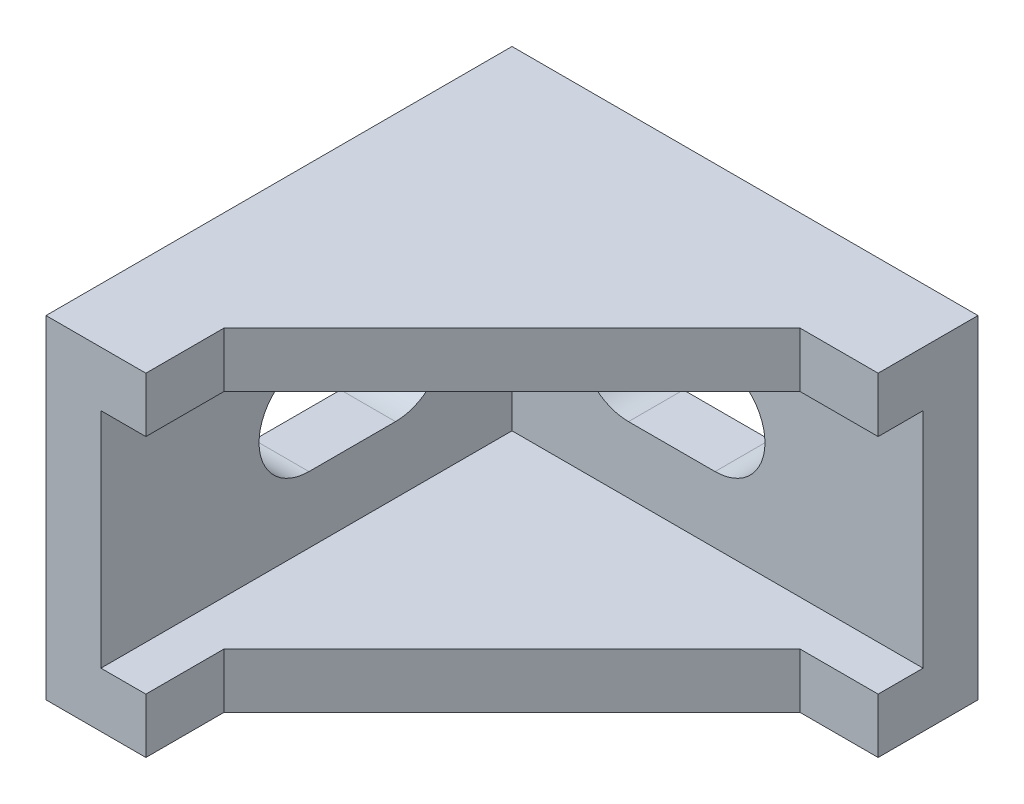
from build123d import *

# Parameters (mm, degrees)
SKETCH1_W           = 28
SKETCH1_H           = 20
BOSS_EXTRUDE1_DEPTH = 3.3
BOSS_EXTRUDE2_DEPTH = 10
SKETCH3_W           = 24.7
SKETCH3_H           = 13.4
CUT_EXTRUDE1_DEPTH  = 24.7


with BuildPart() as part:
    # Sketch1 → Boss-Extrude1 (new body)
    with BuildSketch(Plane(origin=(0, 0, 0), x_dir=(0, 0, -1), z_dir=(1, 0, 0))):
        with Locations((14, 10)):
            Rectangle(SKETCH1_W, SKETCH1_H)
        with BuildLine():
            Line((12.5, 13.28), (17.7, 13.28))
            ThreePointArc((17.7, 13.28), (20.7, 10.28), (17.7, 7.28))
            Line((17.7, 7.28), (12.5, 7.28))
            ThreePointArc((12.5, 7.28), (9.5, 10.28), (12.5, 13.28))
        make_face(mode=Mode.SUBTRACT)
    boss_extrude1 = extrude(amount=BOSS_EXTRUDE1_DEPTH)

    # Mirror1: Boss-Extrude1 across plane
    add(boss_extrude1.mirror(Plane(origin=(14, 0, -14), x_dir=(0.707106781, 0, 0.707106781), z_dir=(-0.707106781, 0, 0.707106781))))

    # Sketch2 → Boss-Extrude2 (add, symmetric)
    with BuildSketch(Plane(origin=(0, 10, 0), x_dir=(1, 0, 0), z_dir=(0, 1, 0))):
        Polygon((3.3, 0), (6, 0), (6, 4.7), (23.3, 22), (28, 22), (28, 24.7), (3.3, 24.7), align=None)
    extrude(amount=BOSS_EXTRUDE2_DEPTH, both=True)

    # Sketch3 → Cut-Extrude1 (cut)
    with BuildSketch(Plane.XY):
        with Locations((15.65, 10)):
            Rectangle(SKETCH3_W, SKETCH3_H)
    extrude(amount=-CUT_EXTRUDE1_DEPTH, mode=Mode.SUBTRACT)


solid = part.part
